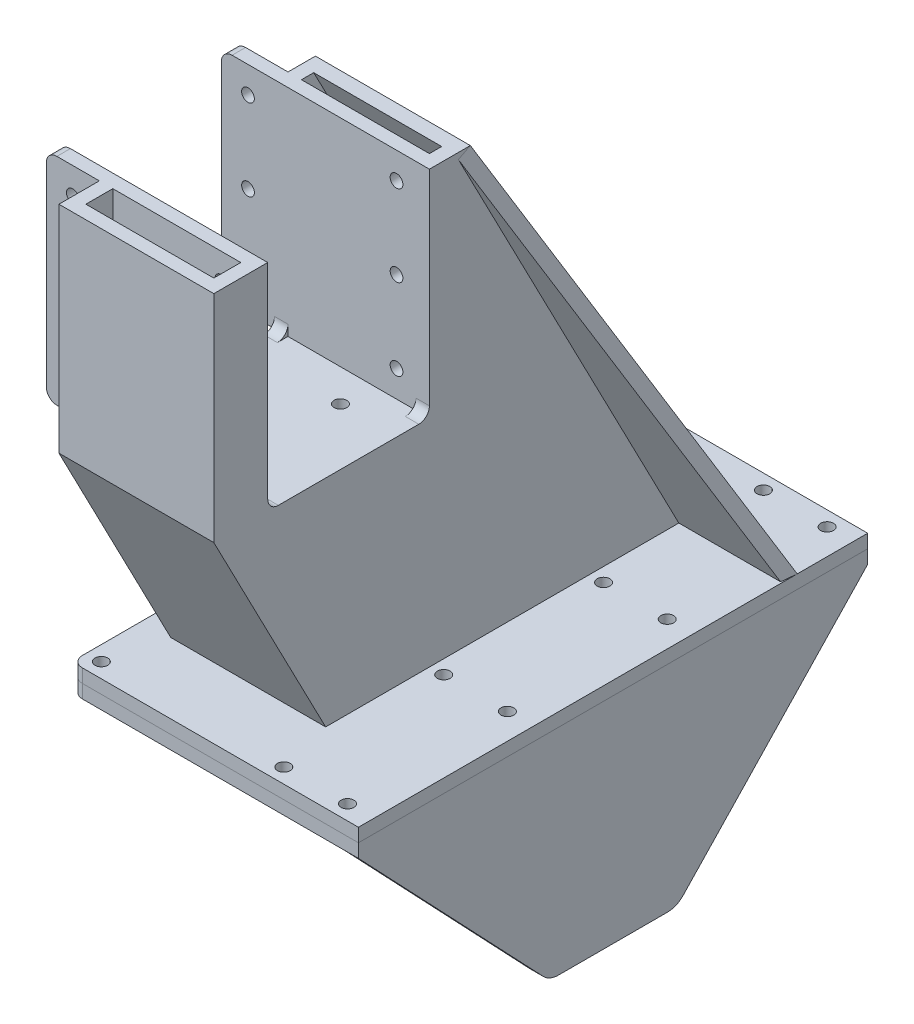
from build123d import *

# Parameters (mm, degrees)
BOSS_EXTRUDE1_START     = 40
BOSS_EXTRUDE1_DEPTH     = 73
SHELL1_T                = -6.35
SKETCH4_W               = 100
SKETCH4_H               = 240
SKETCH4_R               = 3
BOSS_EXTRUDE2_DEPTH     = 6.35
FILLET1_R               = 5
SKETCH5_W               = 76.2
SKETCH5_H               = 101.6
CUT_EXTRUDE2_DEPTH      = 54.5
CUT_EXTRUDE2_DEPTH_BACK = 47.5
FILLET2_R               = 5
CUT_EXTRUDE4_DEPTH      = 45.35
SKETCH11_W              = 6.35
SKETCH11_H              = 101.6
BOSS_EXTRUDE4_DEPTH     = 98
SKETCH12_W              = 88.9
SKETCH12_H              = 6.35
BOSS_EXTRUDE6_DEPTH     = 66.65
SKETCH13_R              = 3
CUT_EXTRUDE5_DEPTH      = 88.9
FILLET5_R               = 5
SKETCH14_R              = 3
CUT_EXTRUDE6_DEPTH      = 14
BOSS_EXTRUDE7_DEPTH     = 240
CUT_EXTRUDE7_DEPTH      = 7.35
FILLET6_R               = 10
SKETCH17_W              = 35.15
SKETCH17_H              = 240
BOSS_EXTRUDE8_DEPTH     = 6.35
SKETCH18_R              = 3
CUT_EXTRUDE8_DEPTH      = 108.5
BOSS_EXTRUDE9_DEPTH     = 6.35


with BuildPart() as part:
    # Sketch1 → Boss-Extrude1 (new body)
    with BuildSketch(Plane(origin=(0, 0, 0), x_dir=(0, 0, -1), z_dir=(1, 0, 0)).offset(BOSS_EXTRUDE1_START)):
        Polygon((-239.752224571, 215.88688855), (-118.868391263, 215.88688855), (-13.457548361, 12.68688855), (-187.04680312, 12.68688855), (-239.752224571, 114.28688855), align=None)
    extrude(amount=-BOSS_EXTRUDE1_DEPTH)

    # Shell1
    shell1_openings = [part.faces().sort_by_distance(p)[0] for p in [
        (3.5, 215.88688855, 179.310307917),
        (3.5, 12.68688855, 100.25217574),
    ]]
    offset(amount=SHELL1_T, openings=shell1_openings, kind=Kind.INTERSECTION)

    # Sketch5 → Cut-Extrude2 (cut, two sides)
    with BuildSketch(Plane(origin=(0, 0, 0), x_dir=(0, 0, -1), z_dir=(1, 0, 0))) as cut_extrude2_sk:
        with Locations((-176.252224571, 165.08688855)):
            Rectangle(SKETCH5_W, SKETCH5_H)
    extrude(amount=CUT_EXTRUDE2_DEPTH, mode=Mode.SUBTRACT)
    extrude(cut_extrude2_sk.sketch, amount=-CUT_EXTRUDE2_DEPTH_BACK, mode=Mode.SUBTRACT)

    # Fillet2
    fillet2_edges = [part.edges().sort_by_distance(p)[0] for p in [
        (36.825, 114.28688855, 214.352224571),
        (-29.825, 114.28688855, 214.352224571),
        (36.825, 114.28688855, 138.152224571),
        (-29.825, 114.28688855, 138.152224571),
    ]]
    fillet(fillet2_edges, radius=FILLET2_R)


with BuildPart() as body_2:
    # Sketch4 → Boss-Extrude2 (new body)
    with BuildSketch(Plane.XZ.offset(-12.68688855)):
        with Locations((3.5, 100.25217574)):
            Rectangle(SKETCH4_W, SKETCH4_H)
        with Locations((46.5, 213.25217574)):
            Circle(SKETCH4_R, mode=Mode.SUBTRACT)
        with Locations((-39.5, 213.25217574)):
            Circle(SKETCH4_R, mode=Mode.SUBTRACT)
        with Locations((46.5, 137.918842407)):
            Circle(SKETCH4_R, mode=Mode.SUBTRACT)
        with Locations((-39.5, 137.918842407)):
            Circle(SKETCH4_R, mode=Mode.SUBTRACT)
        with Locations((46.5, 62.585509074)):
            Circle(SKETCH4_R, mode=Mode.SUBTRACT)
        with Locations((46.5, -12.74782426)):
            Circle(SKETCH4_R, mode=Mode.SUBTRACT)
        with Locations((-39.5, -12.74782426)):
            Circle(SKETCH4_R, mode=Mode.SUBTRACT)
        with Locations((-39.5, 62.585509074)):
            Circle(SKETCH4_R, mode=Mode.SUBTRACT)
    extrude(amount=BOSS_EXTRUDE2_DEPTH)

    # Fillet1
    fillet1_edges = [body_2.edges().sort_by_distance(p)[0] for p in [
        (-46.5, 9.51188855, 220.25217574),
        (-46.5, 9.51188855, -19.74782426),
    ]]
    fillet(fillet1_edges, radius=FILLET1_R)


with BuildPart() as body_3:
    # Mirror1: mirrored copy
    add(body_2.part.mirror(Plane(origin=(0, 6.33688855, 0), x_dir=(0, 0, 1), z_dir=(0, -1, 0))))

    # Sketch15 → Boss-Extrude7 (add)
    with BuildSketch(Plane(origin=(0, 0, -19.74782426), x_dir=(-1, 0, 0), z_dir=(0, 0, -1))):
        Polygon((-53.5, -0.01311145), (-82.3, -0.01311145), (-82.3, -94.81311145), (-88.65, -94.81311145), (-88.65, 6.33688855), (-53.5, 6.33688855), align=None)
    extrude(amount=-BOSS_EXTRUDE7_DEPTH)

    # Sketch16 → Cut-Extrude7 (cut, through all)
    with BuildSketch(Plane.ZY.offset(-82.3)):
        Polygon((-19.74782426, -0.01311145), (70.25217574, -94.81311145), (130.25217574, -94.81311145), (220.25217574, -0.01311145), (220.25217574, -200.01311145), (-19.74782426, -200.01311145), align=None)
    extrude(amount=-CUT_EXTRUDE7_DEPTH, mode=Mode.SUBTRACT)

    # Fillet6
    fillet6_edges = [body_3.edges().sort_by_distance(p)[0] for p in [
        (85.475, -94.81311145, 70.25217574),
        (85.475, -94.81311145, 130.25217574),
    ]]
    fillet(fillet6_edges, radius=FILLET6_R)


with BuildPart() as body_2_1:
    add(body_2.part)

    # Sketch10 → Cut-Extrude4 (cut)
    with BuildSketch(Plane.XZ.offset(0.01311145)):
        with BuildLine():
            Line((-16.5, 175.25217574), (23.5, 175.25217574))
            ThreePointArc((23.5, 175.25217574), (27.035533906, 173.787709646), (28.5, 170.25217574))
            Line((28.5, 170.25217574), (28.5, 30.25217574))
            ThreePointArc((28.5, 30.25217574), (27.035533906, 26.716641834), (23.5, 25.25217574))
            Line((23.5, 25.25217574), (-16.5, 25.25217574))
            ThreePointArc((-16.5, 25.25217574), (-20.035533906, 26.716641834), (-21.5, 30.25217574))
            Line((-21.5, 30.25217574), (-21.5, 170.25217574))
            ThreePointArc((-21.5, 170.25217574), (-20.035533906, 173.787709646), (-16.5, 175.25217574))
        make_face()
    extrude(amount=-CUT_EXTRUDE4_DEPTH, mode=Mode.SUBTRACT)

    # Combine1: union part
    add(part.part)

    # Sketch11 → Boss-Extrude4 (add)
    with BuildSketch(Plane(origin=(40, 0, 0), x_dir=(0, 0, -1), z_dir=(1, 0, 0))):
        with Locations((-217.527224571, 165.08688855)):
            Rectangle(SKETCH11_W, SKETCH11_H)
        with Locations((-134.977224571, 165.08688855)):
            Rectangle(SKETCH11_W, SKETCH11_H)
    extrude(amount=-BOSS_EXTRUDE4_DEPTH)

    # Sketch12 → Boss-Extrude6 (add)
    with BuildSketch(Plane(origin=(40, 0, 0), x_dir=(0, 0, -1), z_dir=(1, 0, 0))):
        with Locations((-176.252224571, 111.11188855)):
            Rectangle(SKETCH12_W, SKETCH12_H)
    extrude(amount=-BOSS_EXTRUDE6_DEPTH)

    # Sketch13 → Cut-Extrude5 (cut)
    with BuildSketch(Plane(origin=(0, 0, 131.802224571), x_dir=(-1, 0, 0), z_dir=(0, 0, -1))):
        with Locations((45.5, 203.38688855)):
            Circle(SKETCH13_R)
        with Locations((45.5, 165.08688855)):
            Circle(SKETCH13_R)
        with Locations((45.5, 126.78688855)):
            Circle(SKETCH13_R)
        with Locations((-24.5, 126.78688855)):
            Circle(SKETCH13_R)
        with Locations((-24.5, 165.08688855)):
            Circle(SKETCH13_R)
        with Locations((-24.5, 203.38688855)):
            Circle(SKETCH13_R)
    extrude(amount=-CUT_EXTRUDE5_DEPTH, mode=Mode.SUBTRACT)

    # Fillet5
    fillet5_edges = [body_2_1.edges().sort_by_distance(p)[0] for p in [
        (-58, 114.28688855, 217.527224571),
        (-58, 215.88688855, 217.527224571),
        (-58, 215.88688855, 134.977224571),
        (-58, 114.28688855, 134.977224571),
    ]]
    fillet(fillet5_edges, radius=FILLET5_R)

    # Sketch14 → Cut-Extrude6 (cut)
    with BuildSketch(Plane(origin=(0, 114.28688855, 0), x_dir=(1, 0, 0), z_dir=(0, 1, 0))):
        with Locations((13.268042809, -153.349971097)):
            Circle(SKETCH14_R)
        with Locations((13.268042809, -199.154478045)):
            Circle(SKETCH14_R)
    extrude(amount=-CUT_EXTRUDE6_DEPTH, mode=Mode.SUBTRACT)

    # Sketch17 → Boss-Extrude8 (add)
    with BuildSketch(Plane(origin=(0, 6.33688855, 0), x_dir=(1, 0, 0), z_dir=(0, 1, 0))):
        with Locations((71.075, -100.25217574)):
            Rectangle(SKETCH17_W, SKETCH17_H)
    extrude(amount=BOSS_EXTRUDE8_DEPTH)


with BuildPart() as cut_extrude8_tool:
    # Sketch18 → Cut-Extrude8 (new body, through all)
    with BuildSketch(Plane(origin=(0, 12.68688855, 0), x_dir=(1, 0, 0), z_dir=(0, 1, 0))):
        with Locations((76.5, 12.74782426)):
            Circle(SKETCH18_R)
        with Locations((76.5, -62.585509074)):
            Circle(SKETCH18_R)
        with Locations((76.5, -137.918842407)):
            Circle(SKETCH18_R)
        with Locations((76.5, -213.25217574)):
            Circle(SKETCH18_R)
    extrude(amount=-CUT_EXTRUDE8_DEPTH)


with BuildPart() as body_2_2:
    add(body_2_1.part)

    # Cut-Extrude8: cut by cut_extrude8_tool
    add(cut_extrude8_tool.part, mode=Mode.SUBTRACT)

    # Sketch19 → Boss-Extrude9 (add)
    with BuildSketch(Plane(origin=(0, -2.810674033, 5.418123485), x_dir=(-1, 0, 0), z_dir=(0, 0.460481998, -0.887669043))):
        Polygon((-40, 246.372862017), (-88.65, 17.458716973), (-40, 17.458716973), align=None)
    extrude(amount=-BOSS_EXTRUDE9_DEPTH)


with BuildPart() as body_3_1:
    add(body_3.part)

    # Cut-Extrude8: cut by cut_extrude8_tool
    add(cut_extrude8_tool.part, mode=Mode.SUBTRACT)


solid = Compound([body_2_2.part, body_3_1.part])
